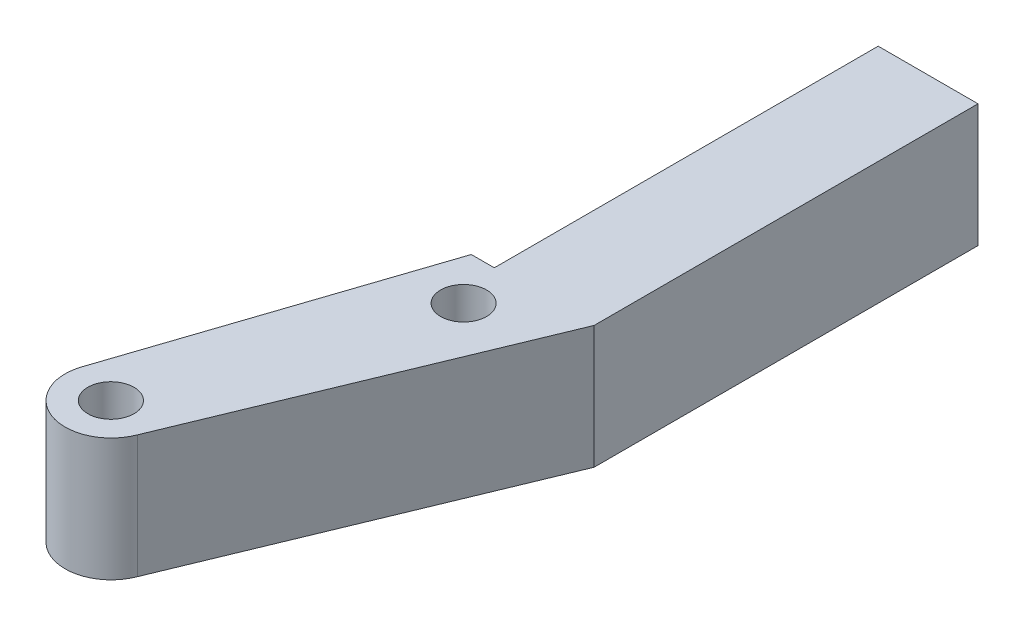
from build123d import *

# Parameters (mm, degrees)
CROQUIS1_R              = 1.5000002
CROQUIS1_R_2            = 1.49999991
SALIENTE_EXTRUIR1_DEPTH = 8


with BuildPart() as part:
    # Croquis1 → Saliente-Extruir1 (new body)
    with BuildSketch(Plane(origin=(0, 0, 0), x_dir=(1, 0, 0), z_dir=(0, 1, 0))):
        with BuildLine():
            Line((-1.19757039, -21.678985349), (7.496084148, -0.648595564))
            Line((7.496084148, -0.648595564), (7.496084148, 24.351404436))
            Line((7.496084148, 24.351404436), (0.996084148, 24.351404436))
            Line((0.996084148, 24.351404436), (0.996084148, -0.648595564))
            Line((0.996084148, -0.648595564), (-0.503915852, -0.648595564))
            Line((-0.503915852, -0.648595564), (-6.872429124, -19.740170948))
            ThreePointArc((-6.872429124, -19.740170948), (-4.970266204, -23.44707843), (-1.19757039, -21.678985349))
        make_face()
        with Locations((1.996084371, -3.648597796)):
            Circle(CROQUIS1_R, mode=Mode.SUBTRACT)
        with Locations((-4.003916027, -20.618596904)):
            Circle(CROQUIS1_R_2, mode=Mode.SUBTRACT)
    extrude(amount=SALIENTE_EXTRUIR1_DEPTH)


solid = part.part
